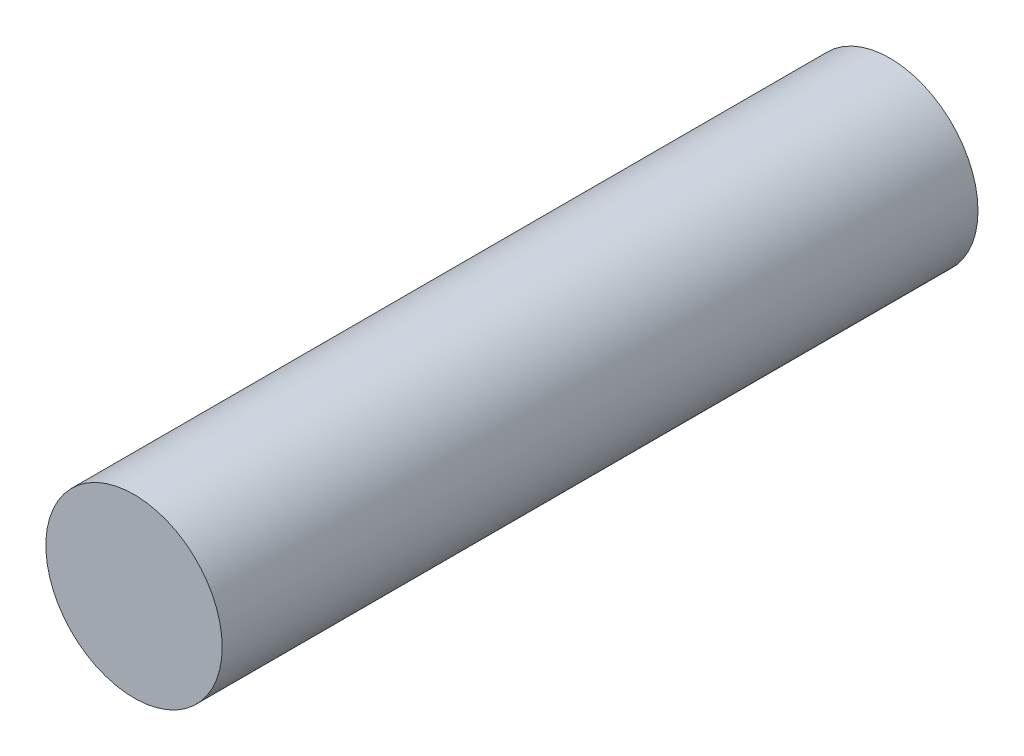
from build123d import *

# Parameters (mm, degrees)
SKETCH1_R           = 3.5
BOSS_EXTRUDE1_DEPTH = 30


with BuildPart() as part:
    # Sketch1 → Boss-Extrude1 (new body)
    with BuildSketch(Plane.XY):
        Circle(SKETCH1_R)
    extrude(amount=BOSS_EXTRUDE1_DEPTH)


solid = part.part
